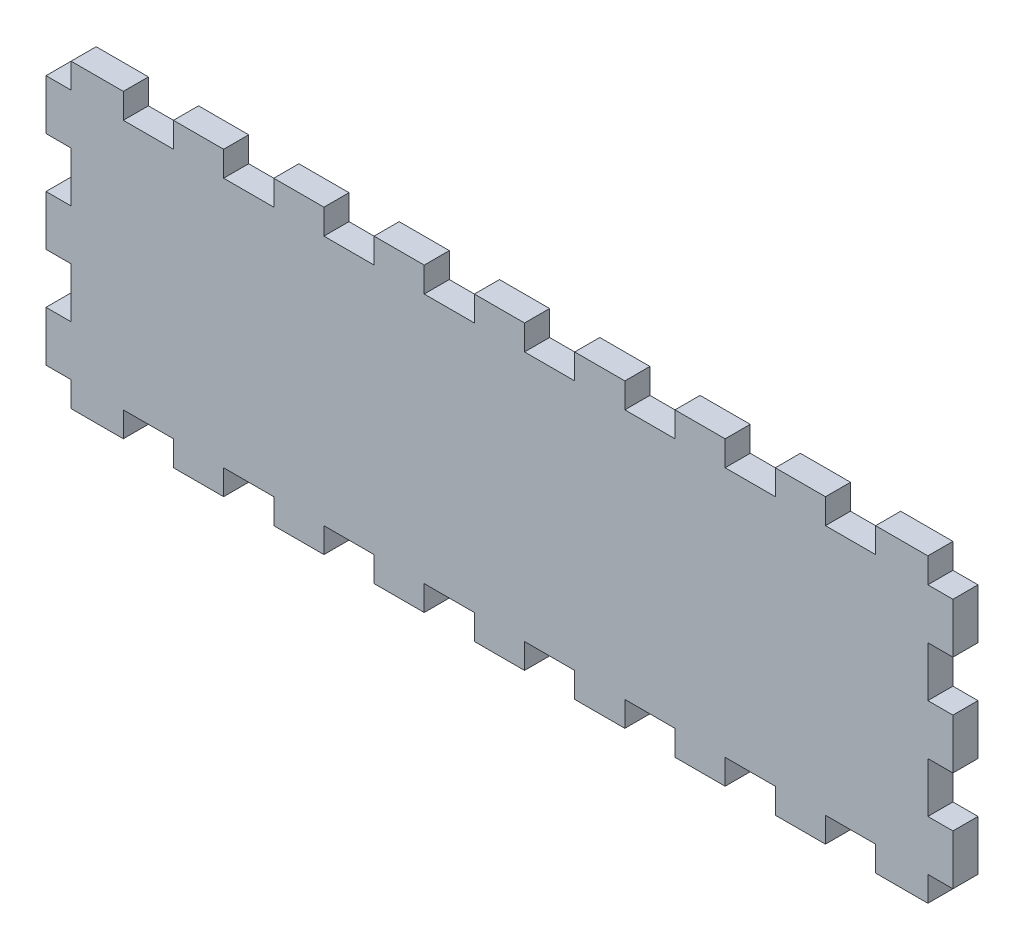
from build123d import *

# Parameters (mm, degrees)
BOSS_EXTRUDE1_DEPTH = 6
SKETCH3_W           = 6
SKETCH3_H           = 12
BOSS_EXTRUDE2_DEPTH = 6


with BuildPart() as part:
    # Sketch2 → Boss-Extrude1 (new body)
    with BuildSketch(Plane.XY.offset(4.036328051)):
        Polygon((-66, 6), (-78, 6), (-78, 0), (-90, 0), (-90, 6), (-102.5, 6), (-102.5, -65.99938194), (-90, -65.99938194), (-90, -59.99938194), (-78, -59.99938194), (-78, -65.99938194), (-66, -65.99938194), (-66, -59.99938194), (-54, -59.99938194), (-54, -65.99938194), (-42, -65.99938194), (-42, -59.99938194), (-30, -59.99938194), (-30, -65.99938194), (-18, -65.99938194), (-18, -59.99938194), (-6, -59.99938194), (-6, -65.99938194), (6, -65.99938194), (6, -59.99938194), (18, -59.99938194), (18, -65.99938194), (30, -65.99938194), (30, -59.99938194), (42, -59.99938194), (42, -65.99938194), (54, -65.99938194), (54, -59.99938194), (66, -59.99938194), (66, -65.99938194), (78, -65.99938194), (78, -59.99938194), (90, -59.99938194), (90, -65.99938194), (102.5, -65.99938194), (102.5, 6), (90, 6), (90, 0), (78, 0), (78, 6), (66, 6), (66, 0), (54, 0), (54, 6), (42, 6), (42, 0), (30, 0), (30, 6), (18, 6), (18, 0), (6, 0), (6, 6), (-6, 6), (-6, 0), (-18, 0), (-18, 6), (-30, 6), (-30, 0), (-42, 0), (-42, 6), (-54, 6), (-54, 0), (-66, 0), align=None)
    extrude(amount=BOSS_EXTRUDE1_DEPTH)

    # Sketch3 → Boss-Extrude2 (add)
    with BuildSketch(Plane.XY.offset(10.036328051)):
        with Locations((-105.5, -6)):
            Rectangle(SKETCH3_W, SKETCH3_H)
        with Locations((105.5, -6)):
            Rectangle(SKETCH3_W, SKETCH3_H)
        with Locations((105.5, -30)):
            Rectangle(SKETCH3_W, SKETCH3_H)
        with Locations((105.5, -54)):
            Rectangle(SKETCH3_W, SKETCH3_H)
        with Locations((-105.5, -30)):
            Rectangle(SKETCH3_W, SKETCH3_H)
        with Locations((-105.5, -54)):
            Rectangle(SKETCH3_W, SKETCH3_H)
    extrude(amount=-BOSS_EXTRUDE2_DEPTH)


solid = part.part
